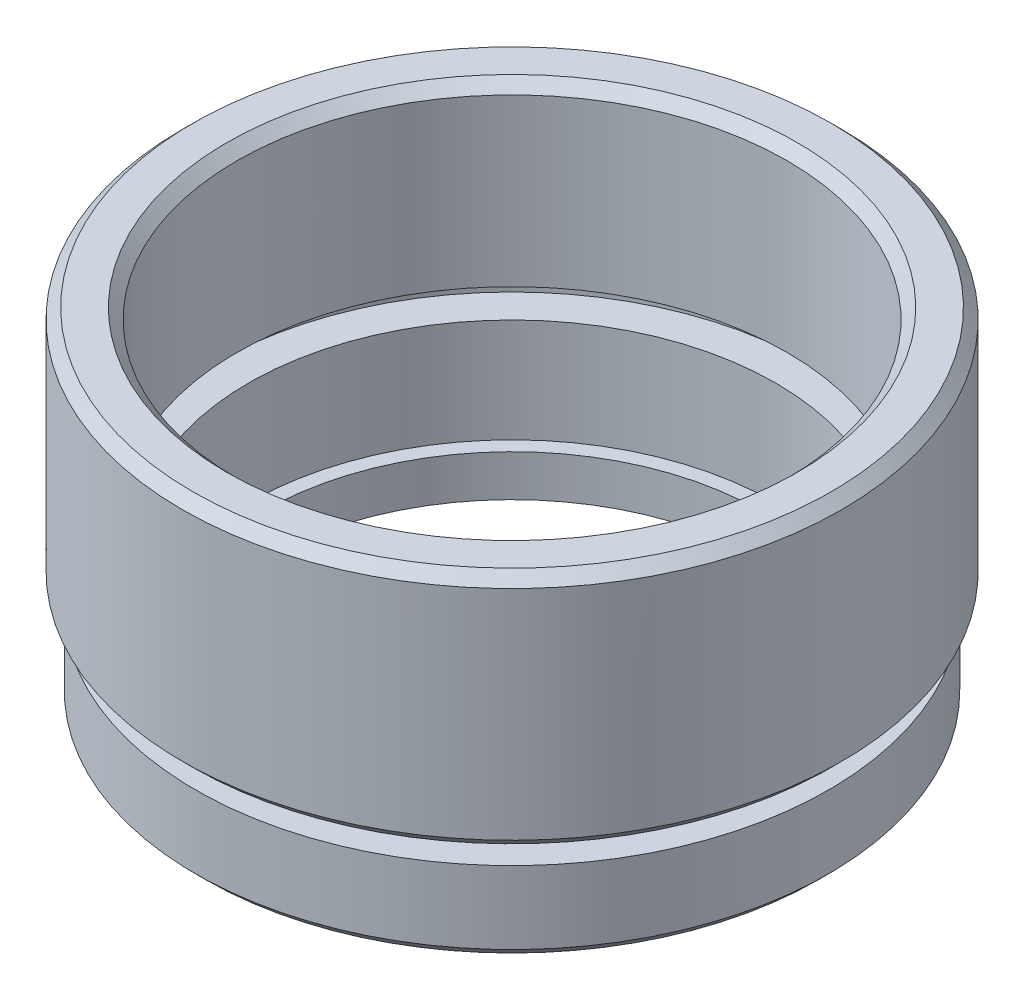
from build123d import *

# Parameters (mm, degrees)
CHAMFER_1_SIZE = 0.5


with BuildPart() as part:
    # 草图1 → 旋转1 (revolve)
    with BuildSketch(Plane.XY, mode=Mode.PRIVATE) as revolve_1_sk:
        Polygon((12, 0), (15.25, 0), (15.25, 4), (13.75, 4), (13.75, 5), (15.875, 5), (15.875, 16.5), (13.25, 16.5), (13.25, 8), (14.35, 8), (14.35, 7), (12.7, 7), (12.7, 2), (12, 2), align=None)
    revolve(revolve_1_sk.sketch.rotate(Axis((0, 0, 0), (0, 1, 0)), 90), axis=Axis((0, 0, 0), (0, 1, 0)))  # turned: the seam where the file's is

    # 倒角1
    chamfer_1_edges = [part.edges().sort_by_distance(p)[0] for p in [
        (0, 16.5, 13.25),
        (0, 16.5, 15.875),
        (0, 5, 15.875),
        (0, 0, 15.25),
    ]]
    chamfer(chamfer_1_edges, length=CHAMFER_1_SIZE)


solid = part.part
